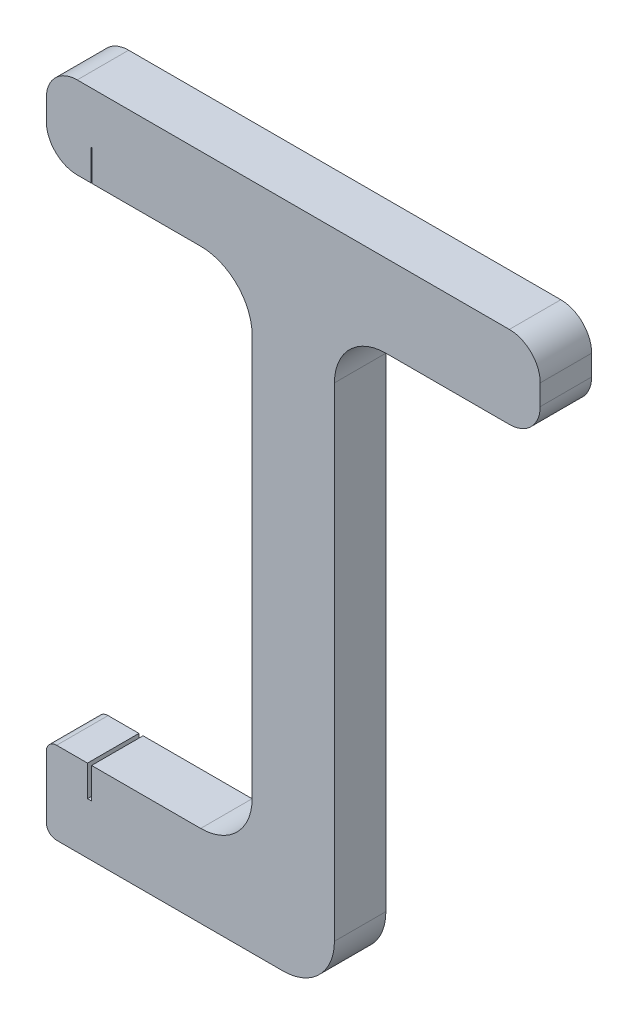
from build123d import *

# Parameters (mm, degrees)
BOSS_EXTRUDE1_DEPTH = 5
SKETCH2_W           = 0.4
SKETCH2_H           = 5
CUT_EXTRUDE1_DEPTH  = 3
SKETCH3_W           = 0.1
SKETCH3_H           = 5
CUT_EXTRUDE2_DEPTH  = 3
FILLET1_R           = 5
FILLET2_R           = 3
FILLET3_R           = 1


with BuildPart() as part:
    # Sketch1 → Boss-Extrude1 (new body)
    with BuildSketch(Plane.XY):
        Polygon((0, 65), (-28, 65), (-28, 57), (-8, 57), (-8, 8), (-28, 8), (-28, 0), (0, 0), (0, 57), (20, 57), (20, 65), align=None)
    extrude(amount=BOSS_EXTRUDE1_DEPTH)

    # Sketch2 → Cut-Extrude1 (cut)
    with BuildSketch(Plane(origin=(0, 8, 0), x_dir=(1, 0, 0), z_dir=(0, 1, 0))):
        with Locations((-23.8, -2.5)):
            Rectangle(SKETCH2_W, SKETCH2_H)
    extrude(amount=-CUT_EXTRUDE1_DEPTH, mode=Mode.SUBTRACT)

    # Sketch3 → Cut-Extrude2 (cut)
    with BuildSketch(Plane.XZ.offset(-57)):
        with Locations((-23.6, 2.5)):
            Rectangle(SKETCH3_W, SKETCH3_H)
    extrude(amount=-CUT_EXTRUDE2_DEPTH, mode=Mode.SUBTRACT)

    # Fillet1
    fillet1_edges = [part.edges().sort_by_distance(p)[0] for p in [
        (0, 57, 2.5),
        (-8, 57, 2.5),
        (0, 0, 2.5),
        (-8, 8, 2.5),
    ]]
    fillet(fillet1_edges, radius=FILLET1_R)

    # Fillet2
    fillet2_edges = [part.edges().sort_by_distance(p)[0] for p in [
        (-28, 57, 2.5),
        (20, 57, 2.5),
        (20, 65, 2.5),
        (-28, 65, 2.5),
    ]]
    fillet(fillet2_edges, radius=FILLET2_R)

    # Fillet3
    fillet3_edges = [part.edges().sort_by_distance(p)[0] for p in [
        (-28, 0, 2.5),
        (-28, 8, 2.5),
    ]]
    fillet(fillet3_edges, radius=FILLET3_R)


solid = part.part
